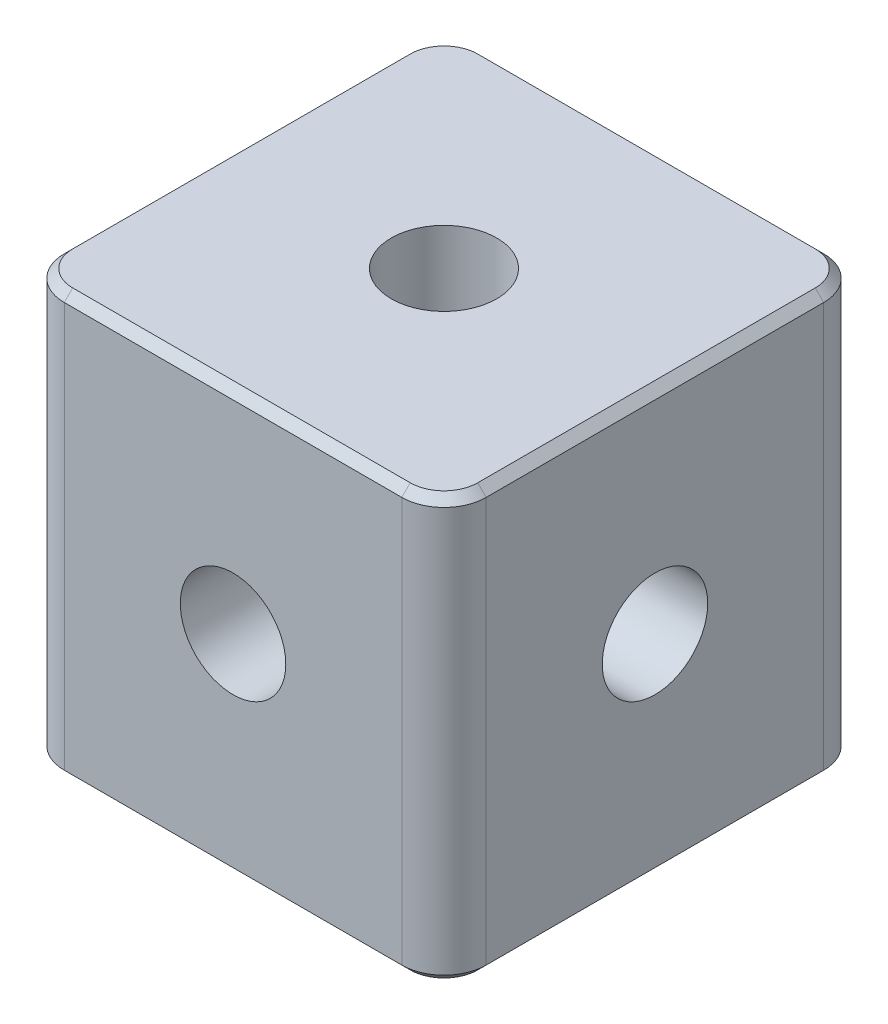
from build123d import *

# Parameters (mm, degrees)
SKETCH_1_W         = 10
SKETCH_1_H         = 10
EXTRUDE_1_DEPTH    = 5
HOLE_WIZARD_M3_1_D = 2.5
HOLE_WIZARD_M3_2_D = 2.5
HOLE_WIZARD_M3_3_D = 2.5
FILLET_1_R         = 1
CHAMFER_1_SIZE     = 0.2


with BuildPart() as part:
    # 草图1 → 凸台-拉伸1 (new body, symmetric)
    with BuildSketch(Plane(origin=(0, 0, 0), x_dir=(1, 0, 0), z_dir=(0, 1, 0))):
        Rectangle(SKETCH_1_W, SKETCH_1_H)
    extrude(amount=EXTRUDE_1_DEPTH, both=True)

    # M3 螺纹孔1 (through all)
    with Locations(Plane(origin=(0, 5, 0), x_dir=(1, 0, 0), z_dir=(0, 1, 0))):
        with Locations((0, 0)):
            Hole(HOLE_WIZARD_M3_1_D / 2)

    # M3 螺纹孔2 (through all)
    with Locations(Plane.XY.offset(5)):
        with Locations((0, 0)):
            Hole(HOLE_WIZARD_M3_2_D / 2)

    # M3 螺纹孔3 (through all)
    with Locations(Plane(origin=(5, 0, 0), x_dir=(0, 0, -1), z_dir=(1, 0, 0))):
        with Locations((0, 0)):
            Hole(HOLE_WIZARD_M3_3_D / 2)

    # 圆角1
    fillet_1_edges = [part.edges().sort_by_distance(p)[0] for p in [
        (5, 0, 5),
        (-5, 0, 5),
        (-5, 0, -5),
        (5, 0, -5),
    ]]
    fillet(fillet_1_edges, radius=FILLET_1_R)

    # 倒角1
    chamfer_1_edges = [part.edges().sort_by_distance(p)[0] for p in [
        (0, -5, -5),
        (0, 5, -5),
        (5, -5, 0),
        (0, -5, 5),
        (-5, -5, 0),
        (-4.707106781, -5, -4.707106781),
        (-4.707106781, -5, 4.707106781),
        (4.707106781, -5, 4.707106781),
        (4.707106781, -5, -4.707106781),
        (5, 5, 0),
        (-5, 5, 0),
        (0, 5, 5),
        (-4.707106781, 5, -4.707106781),
        (-4.707106781, 5, 4.707106781),
        (4.707106781, 5, 4.707106781),
        (4.707106781, 5, -4.707106781),
    ]]
    chamfer(chamfer_1_edges, length=CHAMFER_1_SIZE)


solid = part.part
